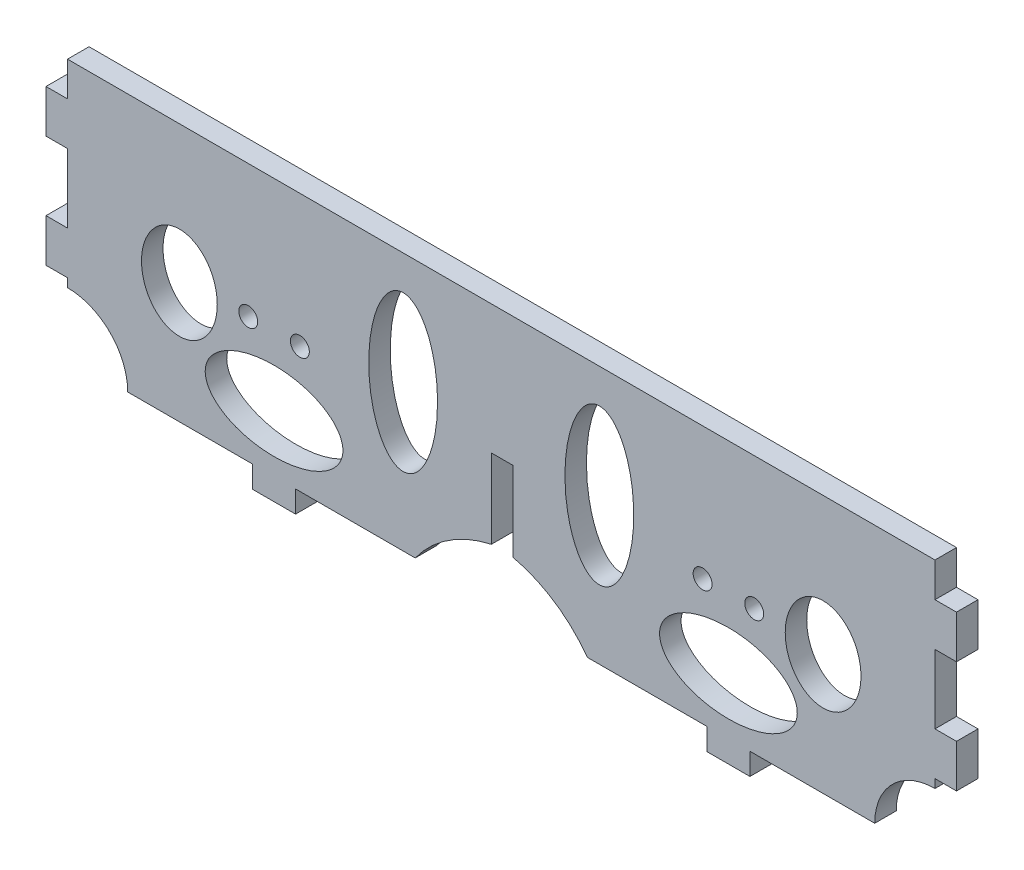
from build123d import *

# Parameters (mm, degrees)
SKETCH1_W                         = 128.016
SKETCH1_H                         = 38.1
MAIN_BODY_DEPTH                   = 3.175
SKETCH2_R                         = 1.397
UBRACKET_HOLES_DEPTH              = 4.175
SKETCH3_W                         = 3.175
SKETCH3_H                         = 6.35
TABS_DEPTH                        = 3.175
SKETCH4_RX                        = 11.43
SKETCH4_RY                        = 5.08
SKETCH4_RX_2                      = 10.16
SKETCH4_RY_2                      = 5.842
SKETCH4_RX_3                      = 6.858
SKETCH4_RY_3                      = 5.588
HOLES_FOR_CONTROL_ARMS_DEPTH      = 4.175
SKETCH5_W                         = 3.175
SKETCH5_H                         = 19.05
SLOT_FOR_NOSE_PANEL_DEPTH         = 4.1750001
CUT_CORNER_FOR_SCREW_ACCESS_DEPTH = 4.1750001


with BuildPart() as part:
    # Sketch1 → main body (new body)
    with BuildSketch(Plane.XY):
        Rectangle(SKETCH1_W, SKETCH1_H)
    extrude(amount=MAIN_BODY_DEPTH)

    # Sketch2 → ubracket holes (cut, through all)
    with BuildSketch(Plane.XY.offset(3.175)):
        with Locations((-29.718, -0.508)):
            Circle(SKETCH2_R)
        with Locations((-37.338, -0.508)):
            Circle(SKETCH2_R)
    ubracket_holes = extrude(amount=-UBRACKET_HOLES_DEPTH, mode=Mode.SUBTRACT)

    # Sketch3 → tabs (add)
    with BuildSketch(Plane.XY.offset(3.175)):
        with Locations((-65.5955, 10.795)):
            Rectangle(SKETCH3_W, SKETCH3_H)
        with Locations((-65.5955, -5.715)):
            Rectangle(SKETCH3_W, SKETCH3_H)
        Polygon((-33.528, -19.05), (-30.353, -19.05), (-30.353, -22.2758), (-36.703, -22.2758), (-36.703, -19.05), align=None)
    tabs = extrude(amount=-TABS_DEPTH)

    # Sketch4 → holes for control arms (cut, through all)
    with BuildSketch(Plane.XY.offset(3.175)):
        with Locations(Location((-14.478, 2.54), (0, 0, 90))):
            Ellipse(SKETCH4_RX, SKETCH4_RY)
        with Locations((-33.527531332, -10.668)):
            Ellipse(SKETCH4_RX_2, SKETCH4_RY_2)
        with Locations(Location((-47.498, -1.27), (0, 0, 90))):
            Ellipse(SKETCH4_RX_3, SKETCH4_RY_3)
    holes_for_control_arms = extrude(amount=-HOLES_FOR_CONTROL_ARMS_DEPTH, mode=Mode.SUBTRACT)

    # mirror of ubracket holes: ubracket holes across plane
    add(ubracket_holes.mirror(Plane(origin=(0, 0, 0), x_dir=(0, 0, 1), z_dir=(1, 0, 0))), mode=Mode.SUBTRACT)

    # mirror of tabs: tabs across plane
    add(tabs.mirror(Plane(origin=(0, 0, 0), x_dir=(0, 0, 1), z_dir=(1, 0, 0))))

    # Mirror3: holes for control arms across plane
    add(holes_for_control_arms.mirror(Plane(origin=(0, 0, 0), x_dir=(0, 0, 1), z_dir=(1, 0, 0))), mode=Mode.SUBTRACT)

    # Sketch5 → slot for nose panel (cut, through all)
    with BuildSketch(Plane.XY.offset(3.175)):
        with Locations((0.130633012, -9.525)):
            Rectangle(SKETCH5_W, SKETCH5_H)
    extrude(amount=-SLOT_FOR_NOSE_PANEL_DEPTH, mode=Mode.SUBTRACT)

    # Sketch6 → cut corner for screw access (cut, through all)
    with BuildSketch(Plane.XY.offset(3.175)):
        with BuildLine():
            Line((0, -19.05), (0, -11.43))
            ThreePointArc((0, -11.43), (-7.135959689, -13.930067184), (-12.7, -19.05))
            Line((-12.7, -19.05), (0, -19.05))
        make_face()
        with BuildLine():
            Line((-64.008, -19.05), (-55.118, -19.05))
            ThreePointArc((-55.118, -19.05), (-57.721820715, -12.763820715), (-64.008, -10.16))
            Line((-64.008, -10.16), (-64.008, -19.05))
        make_face()
    cut_corner_for_screw_access = extrude(amount=-CUT_CORNER_FOR_SCREW_ACCESS_DEPTH, mode=Mode.SUBTRACT)

    # Mirror4: cut corner for screw access across plane
    add(cut_corner_for_screw_access.mirror(Plane(origin=(0, 0, 0), x_dir=(0, 0, 1), z_dir=(1, 0, 0))), mode=Mode.SUBTRACT)


solid = part.part
